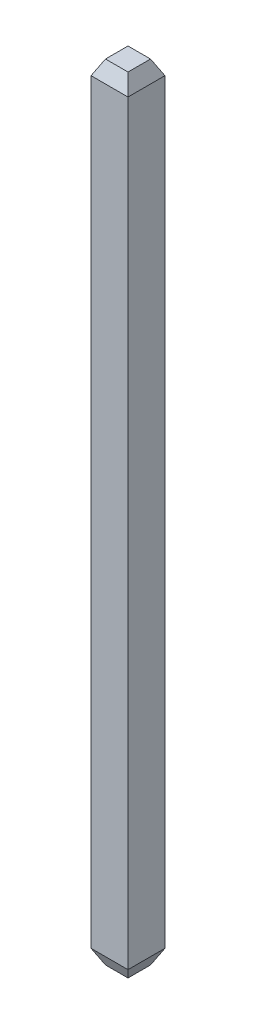
from build123d import *

# Parameters (mm, degrees)
SKETCH1_W             = 0.64
SKETCH1_H             = 0.64
EXTRUDE1_DEPTH        = 13.59
CHAMFER1_SIZE         = 0.25
CHAMFER1_SIZE2        = 0.125
CHAMFER1_PART_2_SIZE  = 0.25
CHAMFER1_PART_2_SIZE2 = 0.125
CHAMFER1_PART_3_SIZE  = 0.25
CHAMFER1_PART_3_SIZE2 = 0.125
CHAMFER1_PART_4_SIZE  = 0.25
CHAMFER1_PART_4_SIZE2 = 0.125
CHAMFER2_SIZE         = 0.125
CHAMFER2_SIZE2        = 0.25


with BuildPart() as part:
    # Sketch1 → Extrude1 (new body)
    with BuildSketch(Plane(origin=(0, 0, 0), x_dir=(1, 0, 0), z_dir=(0, 1, 0))):
        Rectangle(SKETCH1_W, SKETCH1_H)
    extrude(amount=EXTRUDE1_DEPTH)

    # Chamfer1
    chamfer1_edges = [part.edges().sort_by_distance(p)[0] for p in [
        (-0.32, 13.59, 0),
    ]]
    chamfer1_side = [part.faces().sort_by_distance(p)[0] for p in [
        (-0.32, 6.795, 0),
    ]]
    chamfer(chamfer1_edges, length=CHAMFER1_SIZE, length2=CHAMFER1_SIZE2, reference=chamfer1_side[0])

    # Chamfer1 part 2
    chamfer1_part_2_edges = [part.edges().sort_by_distance(p)[0] for p in [
        (0, 13.59, 0.32),
    ]]
    chamfer1_part_2_side = [part.faces().sort_by_distance(p)[0] for p in [
        (0, 6.795, 0.32),
    ]]
    chamfer(chamfer1_part_2_edges, length=CHAMFER1_PART_2_SIZE, length2=CHAMFER1_PART_2_SIZE2, reference=chamfer1_part_2_side[0])

    # Chamfer1 part 3
    chamfer1_part_3_edges = [part.edges().sort_by_distance(p)[0] for p in [
        (0.32, 13.59, 0),
    ]]
    chamfer1_part_3_side = [part.faces().sort_by_distance(p)[0] for p in [
        (0.32, 6.795, 0),
    ]]
    chamfer(chamfer1_part_3_edges, length=CHAMFER1_PART_3_SIZE, length2=CHAMFER1_PART_3_SIZE2, reference=chamfer1_part_3_side[0])

    # Chamfer1 part 4
    chamfer1_part_4_edges = [part.edges().sort_by_distance(p)[0] for p in [
        (0, 13.59, -0.32),
    ]]
    chamfer1_part_4_side = [part.faces().sort_by_distance(p)[0] for p in [
        (0, 6.795, -0.32),
    ]]
    chamfer(chamfer1_part_4_edges, length=CHAMFER1_PART_4_SIZE, length2=CHAMFER1_PART_4_SIZE2, reference=chamfer1_part_4_side[0])

    # Chamfer2
    chamfer2_edges = [part.edges().sort_by_distance(p)[0] for p in [
        (0, 0, 0.32),
        (-0.32, 0, 0),
        (0, 0, -0.32),
        (0.32, 0, 0),
    ]]
    chamfer2_side = [part.faces().sort_by_distance(p)[0] for p in [
        (0, 0, 0),
    ]]
    chamfer(chamfer2_edges, length=CHAMFER2_SIZE, length2=CHAMFER2_SIZE2, reference=chamfer2_side[0])


solid = part.part
